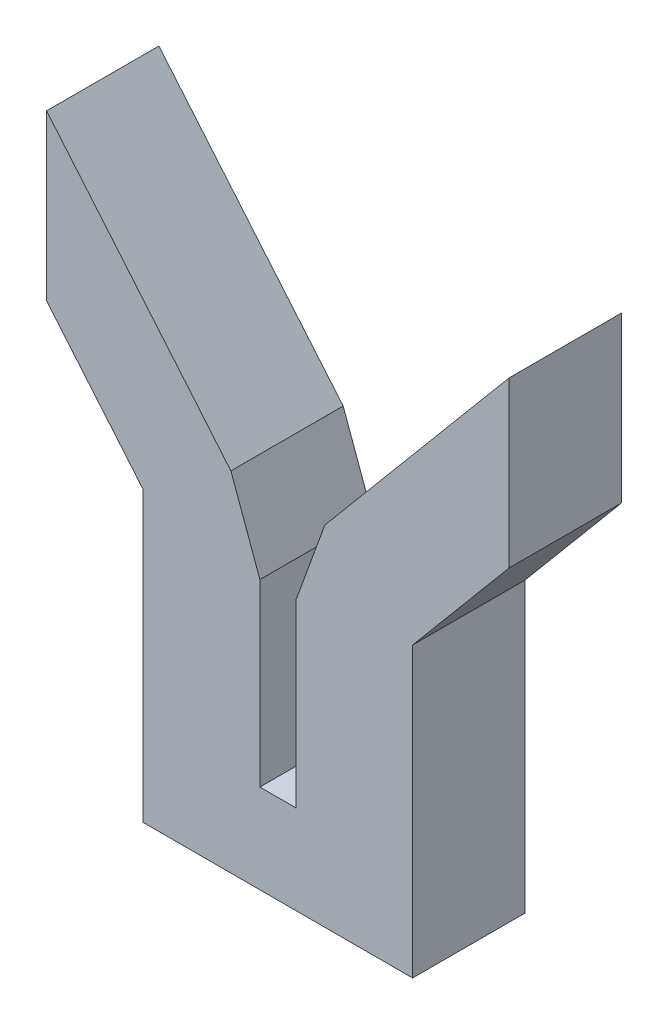
from build123d import *

# Parameters (mm, degrees)
BOSS_EXTRUDE1_DEPTH = 12.5


with BuildPart() as part:
    # Sketch4 → Boss-Extrude1 (new body)
    with BuildSketch(Plane.XY):
        Polygon((15, 32.102616066), (15, 29.909064249), (2, 29.909064249), (5.227521969, 38.776607979), (15.250051757, 50.72099386), (25.745438879, 63.228909169), (25.745438879, 44.908531455), align=None)
        Polygon((-2, 29.909064249), (-15, 29.909064249), (-15, 32.102616066), (-25.745438879, 44.908531455), (-25.745438879, 63.228909169), (-15.250051757, 50.72099386), (-5.227521969, 38.776607979), align=None)
        Polygon((-2, 29.909064249), (-2, 9.909064249), (2, 9.909064249), (2, 29.909064249), (15, 29.909064249), (15, 0), (-15, 0), (-15, 29.909064249), align=None)
    extrude(amount=BOSS_EXTRUDE1_DEPTH)


solid = part.part
